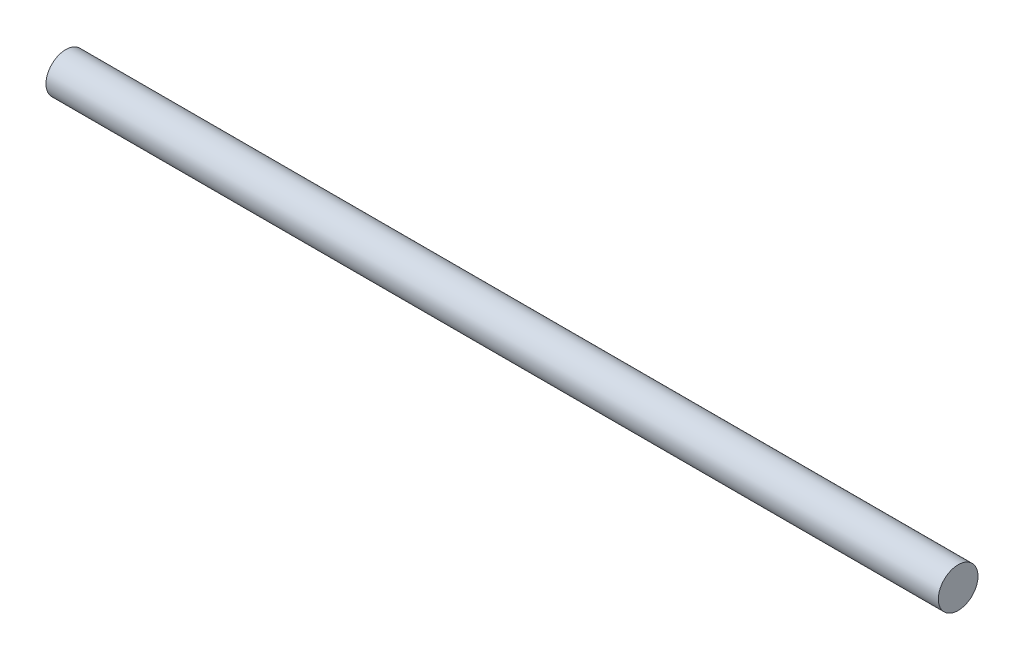
from build123d import *

# Parameters (mm, degrees)
SKETCH1_R           = 10
BOSS_EXTRUDE1_DEPTH = 450


with BuildPart() as part:
    # Sketch1 → Boss-Extrude1 (new body)
    with BuildSketch(Plane(origin=(0, 0, 0), x_dir=(0, 0, -1), z_dir=(1, 0, 0))):
        Circle(SKETCH1_R)
    extrude(amount=BOSS_EXTRUDE1_DEPTH)


solid = part.part
